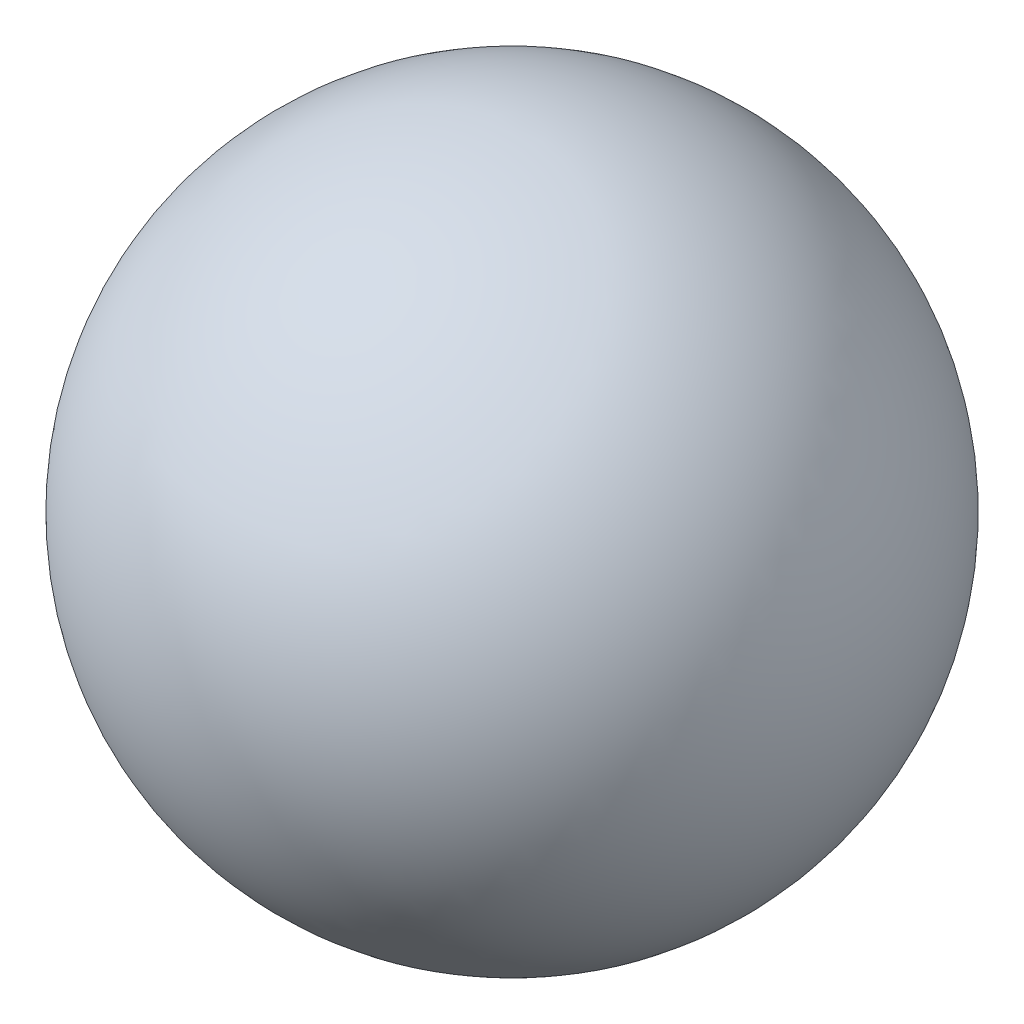
from build123d import *


with BuildPart() as part:
    # Sketch1 → Complete_Ball (revolve)
    with BuildSketch(Plane.XY):
        with BuildLine():
            Line((0, 6.35), (0, -6.35))
            ThreePointArc((0, -6.35), (6.35, 0), (0, 6.35))
        make_face()
    revolve(axis=Axis((0, 6.985, 0), (0, -1, 0)))


solid = part.part
